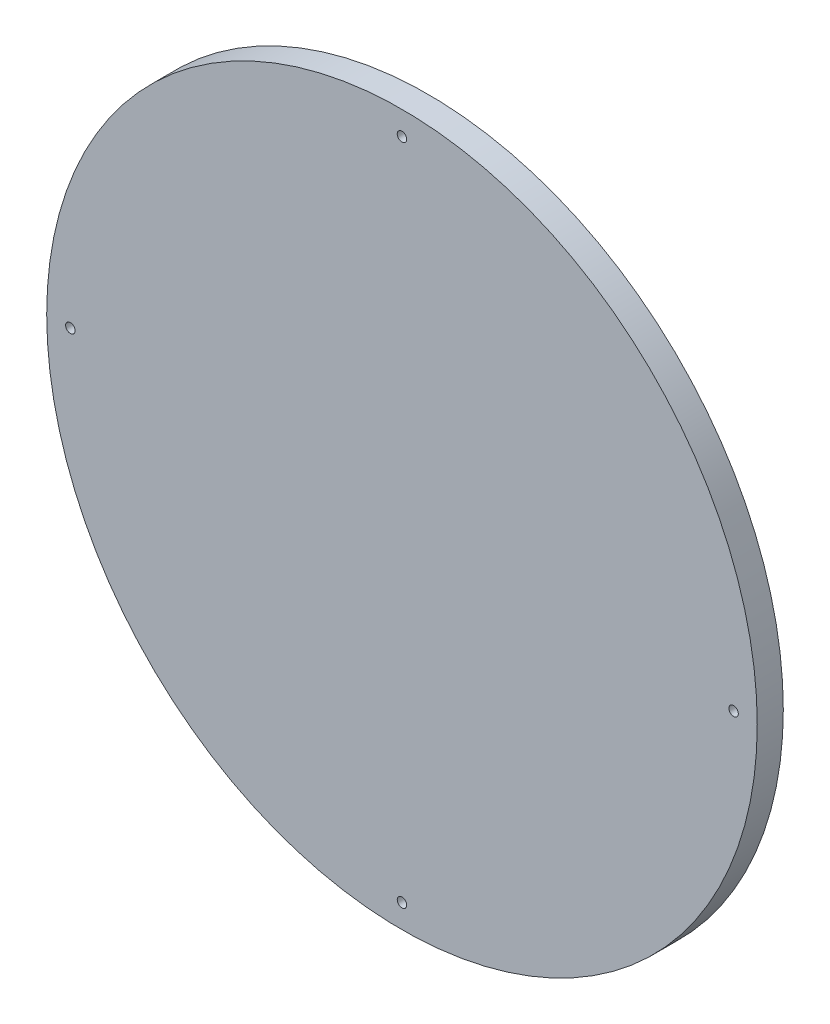
from build123d import *

# Parameters (mm, degrees)
ESQUISSE1_R                  = 300
BOSS_EXTRU_1_DEPTH           = 22
ESQUISSE2_R                  = 4
ENL_V_MAT_EXTRU_1_DEPTH      = 23
R_P_TITION_CIRCULAIRE1_COUNT = 4
ESQUISSE4_R                  = 12
ENL_V_MAT_EXTRU_2_DEPTH      = 5


with BuildPart() as part:
    # Esquisse1 → Boss.-Extru.1 (new body)
    with BuildSketch(Plane.XY):
        Circle(ESQUISSE1_R)
    extrude(amount=BOSS_EXTRU_1_DEPTH)

    # Esquisse2 → Enlèv. mat.-Extru.1 (cut, through all)
    with BuildSketch(Plane.XY.offset(22)):
        with Locations((0, 280)):
            Circle(ESQUISSE2_R)
    enl_v_mat_extru_1 = extrude(amount=-ENL_V_MAT_EXTRU_1_DEPTH, mode=Mode.SUBTRACT)

    # Répétition circulaire1: Enlèv. mat.-Extru.1 ×4 about axis
    r_p_tition_circulaire1_axis = Axis((0, 0, 0), (0, 0, 1))
    for i in range(1, R_P_TITION_CIRCULAIRE1_COUNT):
        add(enl_v_mat_extru_1.rotate(r_p_tition_circulaire1_axis, i * 360 / R_P_TITION_CIRCULAIRE1_COUNT), mode=Mode.SUBTRACT)

    # Esquisse4 → Enlèv. mat.-Extru.2 (cut)
    with BuildSketch(Plane(origin=(0, 0, 0), x_dir=(-1, 0, 0), z_dir=(0, 0, -1))):
        with Locations((0, 280)):
            Circle(ESQUISSE4_R)
    extrude(amount=-ENL_V_MAT_EXTRU_2_DEPTH, mode=Mode.SUBTRACT)


solid = part.part
